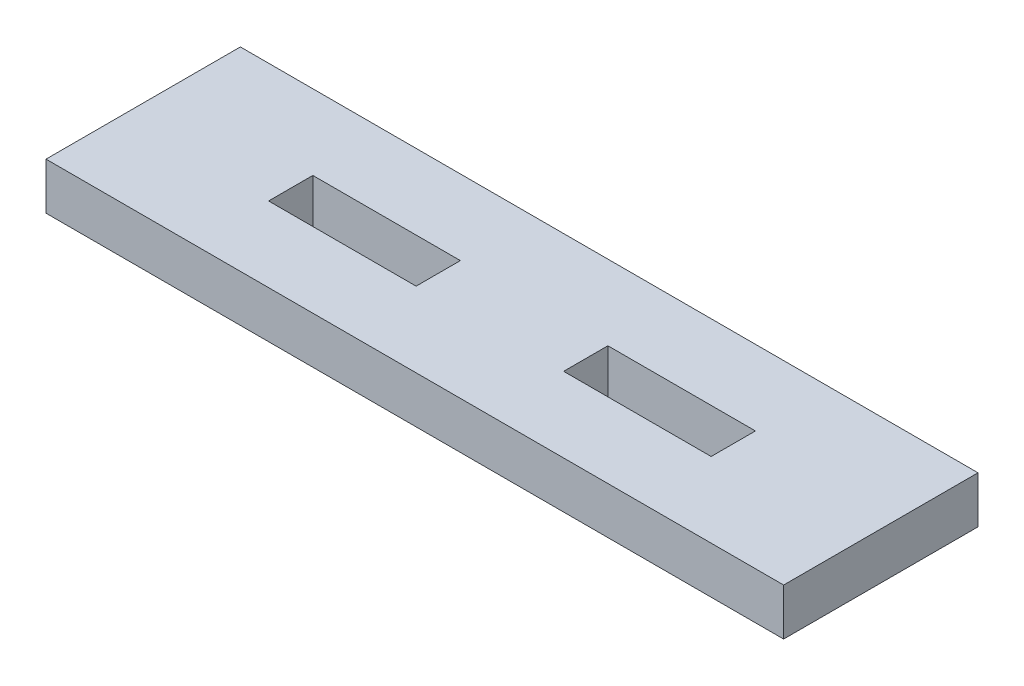
from build123d import *

# Parameters (mm, degrees)
SKETCH1_W           = 50
SKETCH1_H           = 13.175
SKETCH1_W_2         = 10
SKETCH1_H_2         = 3
BOSS_EXTRUDE1_DEPTH = 3.175


with BuildPart() as part:
    # Sketch1 → Boss-Extrude1 (new body)
    with BuildSketch(Plane(origin=(0, 0, 0), x_dir=(1, 0, 0), z_dir=(0, 1, 0))):
        with Locations((25, 6.5875)):
            Rectangle(SKETCH1_W, SKETCH1_H)
        with Locations((35, 6.5875)):
            Rectangle(SKETCH1_W_2, SKETCH1_H_2, mode=Mode.SUBTRACT)
        with Locations((15, 6.5875)):
            Rectangle(SKETCH1_W_2, SKETCH1_H_2, mode=Mode.SUBTRACT)
    extrude(amount=BOSS_EXTRUDE1_DEPTH)


solid = part.part
